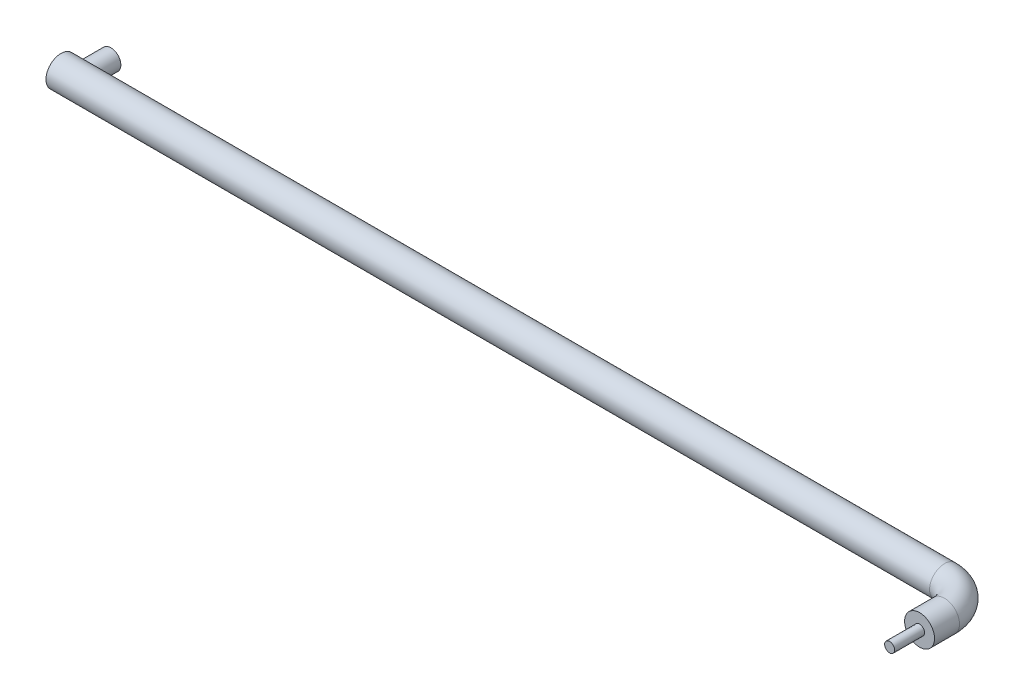
from build123d import *

# Parameters (mm, degrees)
SKETCH2_R           = 15
SKETCH3_R           = 5
BOSS_EXTRUDE1_DEPTH = 30
SKETCH4_R           = 10
BOSS_EXTRUDE2_DEPTH = 35


with BuildPart() as part:
    # Sweep2: sweep along a path in Sketch1
    with BuildLine(Plane(origin=(0, 0, 0), x_dir=(1, 0, 0), z_dir=(0, 1, 0))) as sweep2_path:
        Line((0, 0), (885, 0))
        ThreePointArc((885, 0), (906.213203436, -8.786796564), (915, -30))
        Line((915, -30), (915, -55))
    # Sketch2 → Sweep2 (sweep)
    with BuildSketch(Plane(origin=(0, 0, 0), x_dir=(0, 0, -1), z_dir=(1, 0, 0))):
        Circle(SKETCH2_R)
    sweep(path=sweep2_path.line)

    # Sketch3 → Boss-Extrude1 (add)
    with BuildSketch(Plane.XY.offset(55)):
        with Locations((915, 0)):
            Circle(SKETCH3_R)
    extrude(amount=BOSS_EXTRUDE1_DEPTH)

    # Sketch4 → Boss-Extrude2 (add)
    with BuildSketch(Plane.XY):
        with Locations((15, 0)):
            Circle(SKETCH4_R)
    extrude(amount=-BOSS_EXTRUDE2_DEPTH)


solid = part.part
